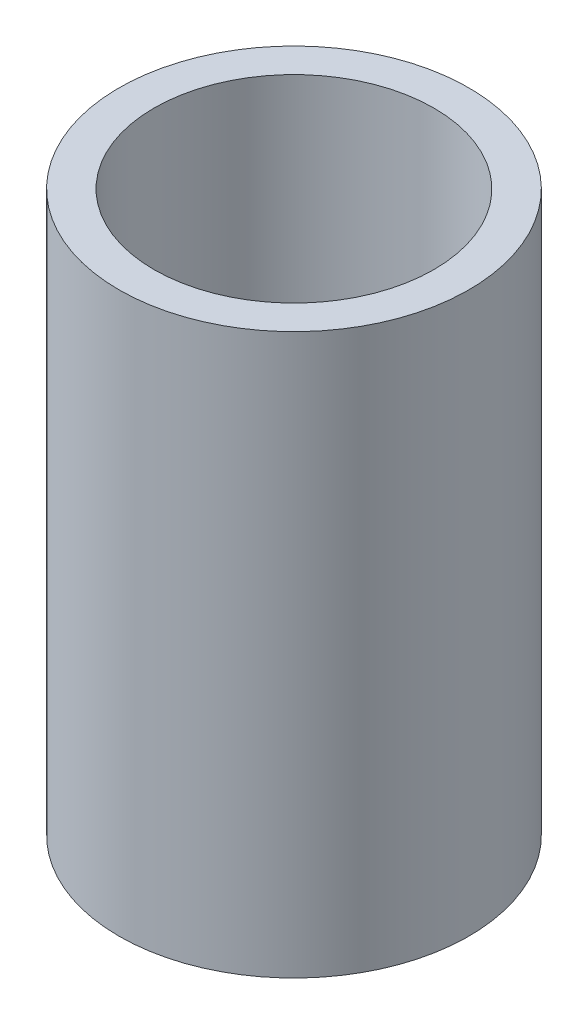
from build123d import *

# Parameters (mm, degrees)
SKETCH1_R           = 7.5
SKETCH1_R_2         = 6
BOSS_EXTRUDE1_DEPTH = 12


with BuildPart() as part:
    # Sketch1 → Boss-Extrude1 (new body, symmetric)
    with BuildSketch(Plane(origin=(0, 0, 0), x_dir=(1, 0, 0), z_dir=(0, 1, 0))):
        Circle(SKETCH1_R)
        Circle(SKETCH1_R_2, mode=Mode.SUBTRACT)
    extrude(amount=BOSS_EXTRUDE1_DEPTH, both=True)


solid = part.part
